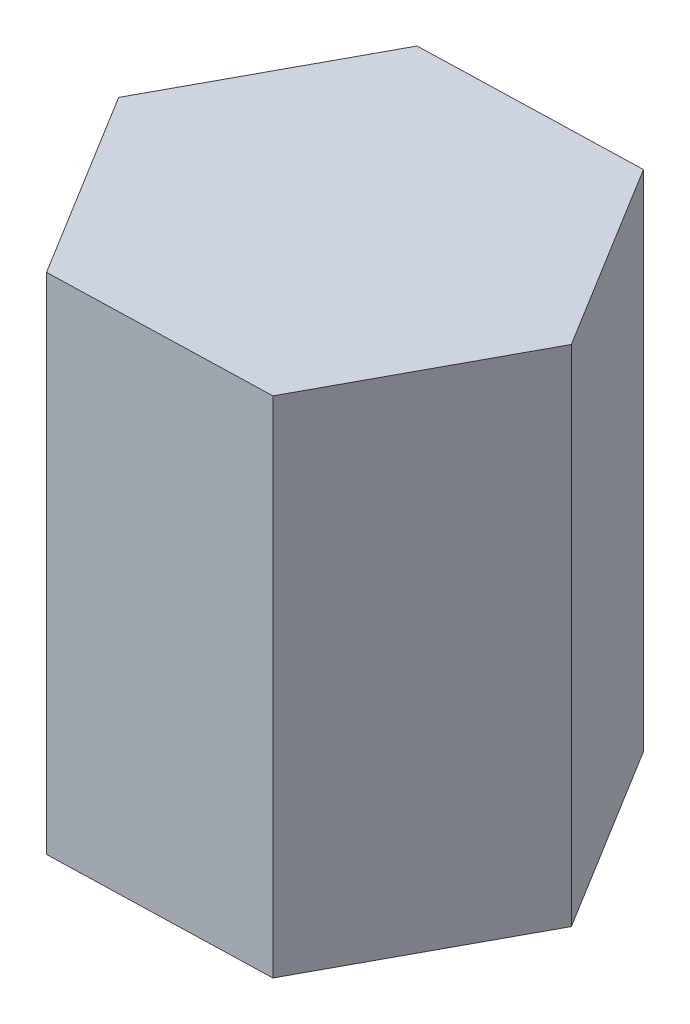
from build123d import *

# Parameters (mm, degrees)
EXTRUDE_1_DEPTH = 100


with BuildPart() as part:
    # 草图1 → 凸台-拉伸1 (new body)
    with BuildSketch(Plane(origin=(0, 0, 0), x_dir=(1, 0, 0), z_dir=(0, 1, 0))):
        Polygon((20.768125051, 38.43451714), (-22.9012057, 37.202982453), (-43.669330751, -1.231534687), (-20.768125051, -38.43451714), (22.9012057, -37.202982453), (43.669330751, 1.231534687), align=None)
    extrude(amount=EXTRUDE_1_DEPTH)


solid = part.part
